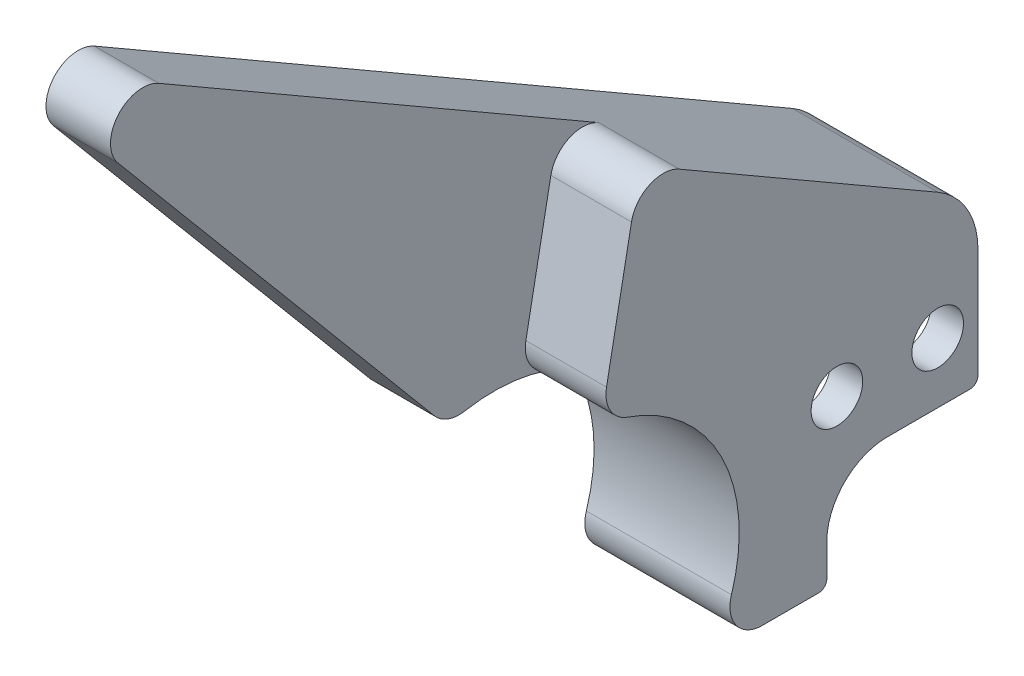
from build123d import *

# Parameters (mm, degrees)
SKETCH1_R           = 2.032
BOSS_EXTRUDE1_DEPTH = 2.54
BOSS_EXTRUDE2_START = -6.35
BOSS_EXTRUDE2_DEPTH = 6.35
BOSS_EXTRUDE3_START = 2.54
SKETCH4_R           = 2.032
BOSS_EXTRUDE3_DEPTH = 2.54
CUT_EXTRUDE2_START  = -6.35
CUT_EXTRUDE2_DEPTH  = 6.35
FILLET1_R           = 2.54
FILLET2_R           = 0.635


with BuildPart() as part:
    # Sketch1 → Boss-Extrude1 (new body)
    # profile 1 of 3: a face of its own
    with BuildSketch(Plane(origin=(0, 0, 0), x_dir=(0, 0, -1), z_dir=(1, 0, 0))):
        with BuildLine():
            Line((-6.736031019, 0), (0, 0))
            Line((0, 0), (0, 17.145))
            Line((0, 17.145), (14.2875, 17.145))
            ThreePointArc((14.2875, 17.145), (13.436761314, 20.32), (11.1125, 22.644261314))
            Line((11.1125, 22.644261314), (-12.333226749, 36.180657964))
            Line((-12.333226749, 36.180657964), (-15.422016596, 20.036703186))
            ThreePointArc((-15.422016596, 20.036703186), (-5.588466213, 12.398528792), (-6.736031019, 0))
        make_face()
    # profile 2 of 3: a face of its own
    with BuildSketch(Plane(origin=(0, 0, 0), x_dir=(0, 0, -1), z_dir=(1, 0, 0))):
        with BuildLine():
            Line((0, 0), (2.38125, 0))
            Line((2.38125, 0), (2.38125, 3.175))
            ThreePointArc((2.38125, 3.175), (3.776153955, 6.542596045), (7.14375, 7.9375))
            Line((7.14375, 7.9375), (14.2875, 7.9375))
            Line((14.2875, 7.9375), (14.2875, 17.145))
            Line((14.2875, 17.145), (0, 17.145))
            Line((0, 17.145), (0, 0))
        make_face()
        with Locations((3.175, 12.7)):
            Circle(SKETCH1_R, mode=Mode.SUBTRACT)
        with Locations((11.1125, 12.7)):
            Circle(SKETCH1_R, mode=Mode.SUBTRACT)
    # profile 3 of 3: a face of its own
    with BuildSketch(Plane(origin=(0, 0, 0), x_dir=(0, 0, -1), z_dir=(1, 0, 0))):
        with BuildLine():
            ThreePointArc((-21.168019902, 19.662272494), (-18.316086524, 20.172801019), (-15.422016596, 20.036703186))
            Line((-15.422016596, 20.036703186), (-12.333226749, 36.180657964))
            Line((-12.333226749, 36.180657964), (-43.88011314, 54.394261314))
            ThreePointArc((-43.88011314, 54.394261314), (-47.095866026, 53.827237317), (-47.095866026, 50.56187626))
            Line((-47.095866026, 50.56187626), (-21.168019902, 19.662272494))
        make_face()
    extrude(amount=BOSS_EXTRUDE1_DEPTH)

    # Sketch1_4 → Boss-Extrude2 (add)
    with BuildSketch(Plane(origin=(0, 0, 0), x_dir=(0, 0, -1), z_dir=(1, 0, 0)).offset(BOSS_EXTRUDE2_START)):
        with BuildLine():
            Line((-6.736031019, 0), (0, 0))
            Line((0, 0), (0, 17.145))
            Line((0, 17.145), (14.2875, 17.145))
            ThreePointArc((14.2875, 17.145), (13.436761314, 20.32), (11.1125, 22.644261314))
            Line((11.1125, 22.644261314), (-12.333226749, 36.180657964))
            Line((-12.333226749, 36.180657964), (-15.422016596, 20.036703186))
            ThreePointArc((-15.422016596, 20.036703186), (-5.588466213, 12.398528792), (-6.736031019, 0))
        make_face()
        with BuildLine():
            ThreePointArc((-21.168019902, 19.662272494), (-18.316086524, 20.172801019), (-15.422016596, 20.036703186))
            Line((-15.422016596, 20.036703186), (-12.333226749, 36.180657964))
            Line((-12.333226749, 36.180657964), (-43.88011314, 54.394261314))
            ThreePointArc((-43.88011314, 54.394261314), (-47.095866026, 53.827237317), (-47.095866026, 50.56187626))
            Line((-47.095866026, 50.56187626), (-21.168019902, 19.662272494))
        make_face()
    extrude(amount=BOSS_EXTRUDE2_DEPTH)

    # Sketch4 → Boss-Extrude3 (add)
    with BuildSketch(Plane.ZY.offset(6.35).offset(BOSS_EXTRUDE3_START)):
        with BuildLine():
            Line((-2.38125, 0), (6.736031019, 0))
            ThreePointArc((6.736031019, 0), (7.030863273, 14.911227359), (21.168019902, 19.662272494))
            Line((21.168019902, 19.662272494), (47.095866026, 50.56187626))
            ThreePointArc((47.095866026, 50.56187626), (47.095866026, 53.827237317), (43.88011314, 54.394261314))
            Line((43.88011314, 54.394261314), (-11.1125, 22.644261314))
            ThreePointArc((-11.1125, 22.644261314), (-13.436761314, 20.32), (-14.2875, 17.145))
            Line((-14.2875, 17.145), (-14.2875, 7.9375))
            Line((-14.2875, 7.9375), (-7.14375, 7.9375))
            ThreePointArc((-7.14375, 7.9375), (-3.776153955, 6.542596045), (-2.38125, 3.175))
            Line((-2.38125, 3.175), (-2.38125, 0))
        make_face()
        with Locations(Location((-3.175, 12.7, 0), (0, 0, 180))):
            Circle(SKETCH4_R, mode=Mode.SUBTRACT)
        with Locations(Location((-11.1125, 12.7, 0), (0, 0, 180))):
            Circle(SKETCH4_R, mode=Mode.SUBTRACT)
    extrude(amount=-BOSS_EXTRUDE3_DEPTH)

    # Sketch5 → Cut-Extrude2 (cut)
    with BuildSketch(Plane(origin=(2.54, 0, 0), x_dir=(0, 0, -1), z_dir=(1, 0, 0)).offset(CUT_EXTRUDE2_START)):
        with BuildLine():
            Line((-15.422016596, 20.036703186), (-12.333226749, 36.180657964))
            Line((-12.333226749, 36.180657964), (-43.88011314, 54.394261314))
            ThreePointArc((-43.88011314, 54.394261314), (-47.095866026, 53.827237317), (-47.095866026, 50.56187626))
            Line((-47.095866026, 50.56187626), (-21.168019902, 19.662272494))
            ThreePointArc((-21.168019902, 19.662272494), (-18.316086524, 20.172801019), (-15.422016596, 20.036703186))
        make_face()
    extrude(amount=CUT_EXTRUDE2_DEPTH, mode=Mode.SUBTRACT)

    # Fillet1
    fillet1_edges = [part.edges().sort_by_distance(p)[0] for p in [
        (-3.175, 0, 6.736031019),
        (-6.35, 19.662272494, 21.168019902),
        (-0.635, 36.180657964, 12.333226749),
        (-0.635, 20.036703186, 15.422016596),
    ]]
    fillet(fillet1_edges, radius=FILLET1_R)

    # Fillet2
    fillet2_edges = [part.edges().sort_by_distance(p)[0] for p in [
        (1.27, 7.9375, -14.2875),
        (1.27, 0, -2.38125),
        (-3.175, 17.145, -14.2875),
        (-3.175, 0, 0),
        (-7.62, 7.9375, -14.2875),
        (-7.62, 0, -2.38125),
    ]]
    fillet(fillet2_edges, radius=FILLET2_R)


solid = part.part
